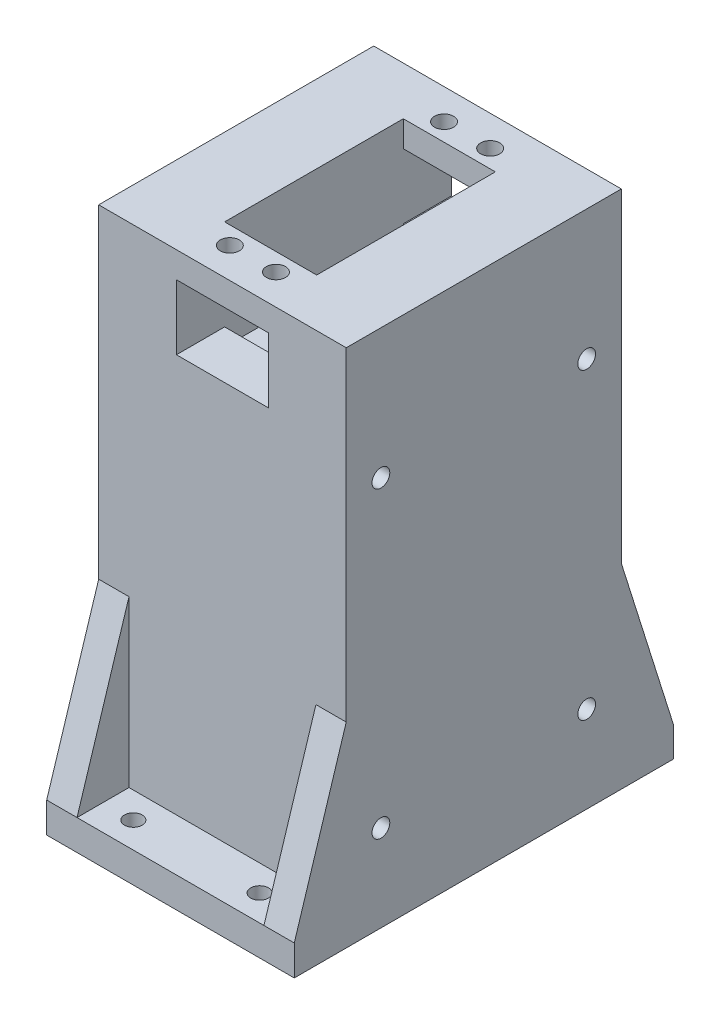
from build123d import *

# Parameters (mm, degrees)
SKETCH1_W           = 57.15
SKETCH1_H           = 63.5
BOSS_EXTRUDE1_DEPTH = 120
SKETCH2_W           = 21.25
SKETCH2_H           = 41.25
CUT_EXTRUDE1_DEPTH  = 25
SKETCH3_R           = 2.2
CUT_EXTRUDE2_DEPTH  = 10
SKETCH4_W           = 21.25
SKETCH4_H           = 15
CUT_EXTRUDE3_DEPTH  = 64.5
SKETCH7_R           = 2.05
CUT_EXTRUDE4_DEPTH  = 58.15
SKETCH9_W           = 12
SKETCH9_H           = 7
BOSS_EXTRUDE2_DEPTH = 57.15
SKETCH10_R          = 2.05
CUT_EXTRUDE5_DEPTH  = 8
BOSS_EXTRUDE3_DEPTH = 7
BOSS_EXTRUDE4_DEPTH = 7
SKETCH13_W          = 21.25
SKETCH13_H          = 20
CUT_EXTRUDE6_DEPTH  = 60


with BuildPart() as part:
    # Sketch1 → Boss-Extrude1 (new body)
    with BuildSketch(Plane(origin=(0, 0, 0), x_dir=(1, 0, 0), z_dir=(0, 1, 0))):
        Rectangle(SKETCH1_W, SKETCH1_H)
    extrude(amount=BOSS_EXTRUDE1_DEPTH)

    # Sketch2 → Cut-Extrude1 (cut)
    with BuildSketch(Plane(origin=(0, 120, 0), x_dir=(1, 0, 0), z_dir=(0, 1, 0))):
        Rectangle(SKETCH2_W, SKETCH2_H)
    extrude(amount=-CUT_EXTRUDE1_DEPTH, mode=Mode.SUBTRACT)

    # Sketch3 → Cut-Extrude2 (cut)
    with BuildSketch(Plane(origin=(0, 120, 0), x_dir=(1, 0, 0), z_dir=(0, 1, 0))):
        with Locations((5.325, 24.725)):
            Circle(SKETCH3_R)
        with Locations((-5.325, 24.725)):
            Circle(SKETCH3_R)
        with Locations((5.325, -24.725)):
            Circle(SKETCH3_R)
        with Locations((-5.325, -24.725)):
            Circle(SKETCH3_R)
    extrude(amount=-CUT_EXTRUDE2_DEPTH, mode=Mode.SUBTRACT)

    # Sketch4 → Cut-Extrude3 (cut, through all)
    with BuildSketch(Plane.XY.offset(31.75)):
        with Locations((0, 106.5)):
            Rectangle(SKETCH4_W, SKETCH4_H)
    extrude(amount=-CUT_EXTRUDE3_DEPTH, mode=Mode.SUBTRACT)

    # Sketch7 → Cut-Extrude4 (cut, through all)
    with BuildSketch(Plane.ZY.offset(28.575)):
        with Locations((23.75, 20)):
            Circle(SKETCH7_R)
        with Locations((23.75, 90)):
            Circle(SKETCH7_R)
        with Locations((-23.75, 20)):
            Circle(SKETCH7_R)
        with Locations((-23.75, 90)):
            Circle(SKETCH7_R)
    extrude(amount=-CUT_EXTRUDE4_DEPTH, mode=Mode.SUBTRACT)

    # Sketch9 → Boss-Extrude2 (add)
    with BuildSketch(Plane(origin=(28.575, 0, 0), x_dir=(0, 0, -1), z_dir=(1, 0, 0))):
        with Locations((37.75, 3.5)):
            Rectangle(SKETCH9_W, SKETCH9_H)
        with Locations((-37.75, 3.5)):
            Rectangle(SKETCH9_W, SKETCH9_H)
    extrude(amount=-BOSS_EXTRUDE2_DEPTH)

    # Sketch10 → Cut-Extrude5 (cut, through all)
    with BuildSketch(Plane(origin=(0, 7, 0), x_dir=(1, 0, 0), z_dir=(0, 1, 0))):
        with Locations((-14.575, 37.75)):
            Circle(SKETCH10_R)
        with Locations((14.575, 37.75)):
            Circle(SKETCH10_R)
        with Locations((14.575, -37.75)):
            Circle(SKETCH10_R)
        with Locations((-14.575, -37.75)):
            Circle(SKETCH10_R)
    extrude(amount=-CUT_EXTRUDE5_DEPTH, mode=Mode.SUBTRACT)

    # Sketch11 → Boss-Extrude3 (add)
    with BuildSketch(Plane(origin=(28.575, 0, 0), x_dir=(0, 0, -1), z_dir=(1, 0, 0))):
        Polygon((-31.75, 45.157568057), (-43.75, 7), (-31.75, 7), align=None)
        Polygon((43.75, 7), (31.75, 7), (31.75, 45.157568057), align=None)
    extrude(amount=-BOSS_EXTRUDE3_DEPTH)

    # Sketch12 → Boss-Extrude4 (add)
    with BuildSketch(Plane.ZY.offset(28.575)):
        Polygon((-31.75, 45.157568057), (-43.75, 7), (-31.75, 7), align=None)
        Polygon((43.75, 7), (31.75, 7), (31.75, 45.157568057), align=None)
    extrude(amount=-BOSS_EXTRUDE4_DEPTH)

    # Sketch13 → Cut-Extrude6 (cut)
    with BuildSketch(Plane(origin=(0, 95, 0), x_dir=(1, 0, 0), z_dir=(0, 1, 0))):
        Rectangle(SKETCH13_W, SKETCH13_H)
    extrude(amount=-CUT_EXTRUDE6_DEPTH, mode=Mode.SUBTRACT)


solid = part.part
